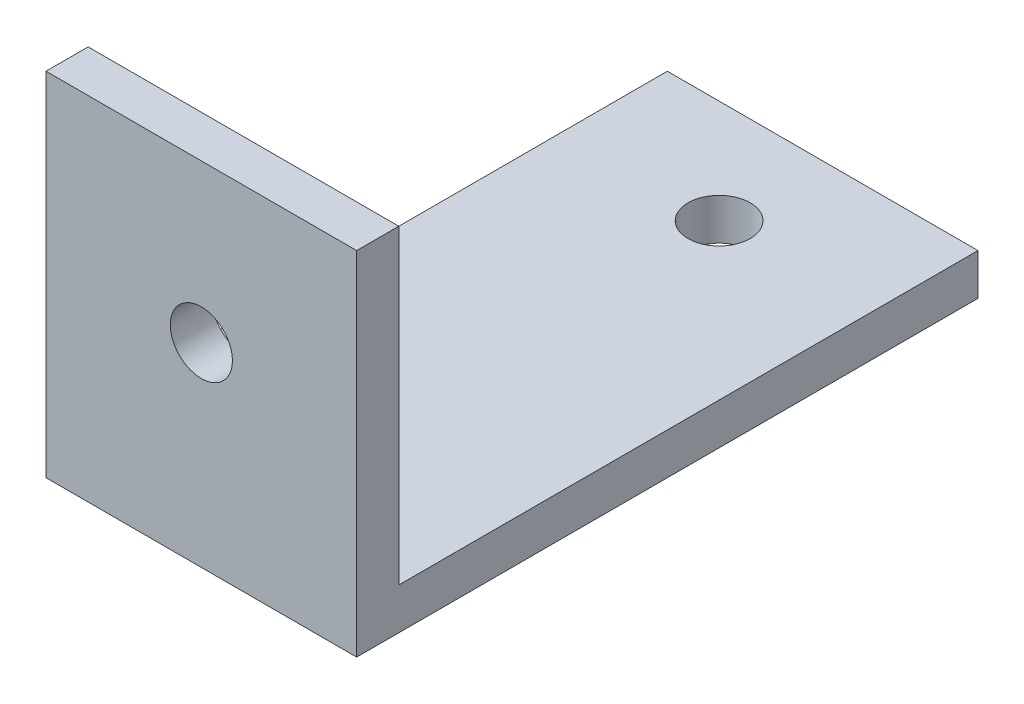
from build123d import *

# Parameters (mm, degrees)
SKETCH1_W           = 15
SKETCH1_H           = 30
SKETCH1_R           = 1.5
BOSS_EXTRUDE1_DEPTH = 2
SKETCH3_W           = 15
SKETCH3_H           = 2.034817015
BOSS_EXTRUDE2_DEPTH = 15
SKETCH4_R           = 1.5
CUT_EXTRUDE1_DEPTH  = 15


with BuildPart() as part:
    # Sketch1 → Boss-Extrude1 (new body)
    with BuildSketch(Plane(origin=(0, 0, 0), x_dir=(1, 0, 0), z_dir=(0, 1, 0))):
        with Locations((-21.737545239, 6.883664284)):
            Rectangle(SKETCH1_W, SKETCH1_H)
        with Locations((-21.737545239, 16.883664284)):
            Circle(SKETCH1_R, mode=Mode.SUBTRACT)
        with Locations((-21.737545239, -3.116335716)):
            Circle(SKETCH1_R, mode=Mode.SUBTRACT)
    extrude(amount=BOSS_EXTRUDE1_DEPTH)

    # Sketch3 → Boss-Extrude2 (add)
    with BuildSketch(Plane(origin=(0, 2, 0), x_dir=(1, 0, 0), z_dir=(0, 1, 0))):
        with Locations((-21.737545239, -7.098927209)):
            Rectangle(SKETCH3_W, SKETCH3_H)
    extrude(amount=BOSS_EXTRUDE2_DEPTH)

    # Sketch4 → Cut-Extrude1 (cut)
    with BuildSketch(Plane(origin=(0, 0, 6.081518701), x_dir=(-1, 0, 0), z_dir=(0, 0, -1))):
        with Locations((21.737545239, 9.398162072)):
            Circle(SKETCH4_R)
    extrude(amount=-CUT_EXTRUDE1_DEPTH, mode=Mode.SUBTRACT)


solid = part.part
